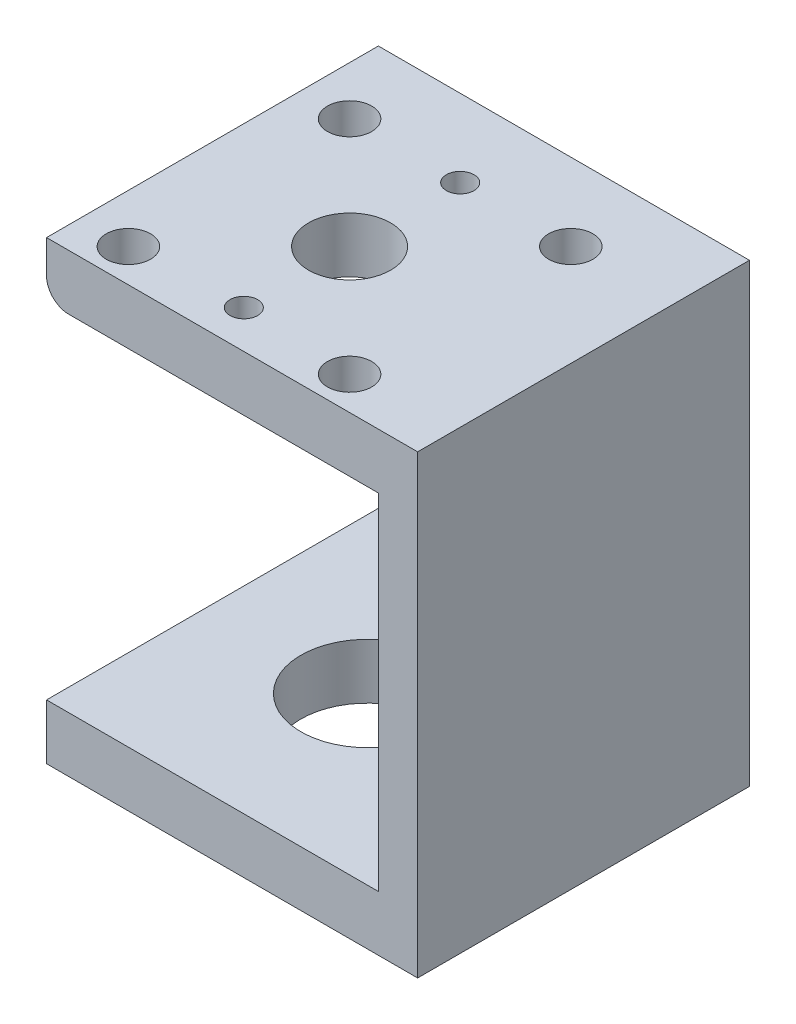
from build123d import *

# Parameters (mm, degrees)
CROQUIS1_W              = 33.552631578
CROQUIS1_H              = 30
SALIENTE_EXTRUIR1_DEPTH = 41.2
CROQUIS2_W              = 30
CROQUIS2_H              = 31.2
CORTAR_EXTRUIR1_DEPTH   = 36.2
CROQUIS3_R              = 2
CROQUIS3_R_2            = 1.25
CROQUIS3_R_3            = 3.71
CORTAR_EXTRUIR2_DEPTH   = 5
CROQUIS4_R              = 6
CORTAR_EXTRUIR3_DEPTH   = 5
REDONDEO1_R             = 2


with BuildPart() as part:
    # Croquis1 → Saliente-Extruir1 (new body)
    with BuildSketch(Plane(origin=(0, 0, 0), x_dir=(1, 0, 0), z_dir=(0, 1, 0))):
        Rectangle(CROQUIS1_W, CROQUIS1_H)
    extrude(amount=SALIENTE_EXTRUIR1_DEPTH)

    # Croquis2 → Cortar-Extruir1 (cut)
    with BuildSketch(Plane.XY.offset(15)):
        with Locations((-1.776315789, 20.6)):
            Rectangle(CROQUIS2_W, CROQUIS2_H)
    extrude(amount=-CORTAR_EXTRUIR1_DEPTH, mode=Mode.SUBTRACT)

    # Croquis3 → Cortar-Extruir2 (cut)
    with BuildSketch(Plane(origin=(0, 41.2, 0), x_dir=(1, 0, 0), z_dir=(0, 1, 0))):
        with Locations((-12.376315789, -12)):
            Circle(CROQUIS3_R)
        with Locations((-2.376315789, -11.563330836)):
            Circle(CROQUIS3_R_2)
        with Locations((7.623684211, -12)):
            Circle(CROQUIS3_R)
        with Locations((-2.376315789, -2)):
            Circle(CROQUIS3_R_3)
        with Locations((7.623684211, 8)):
            Circle(CROQUIS3_R)
        with Locations((-2.376315789, 8)):
            Circle(CROQUIS3_R_2)
        with Locations((-12.376315789, 8)):
            Circle(CROQUIS3_R)
    extrude(amount=-CORTAR_EXTRUIR2_DEPTH, mode=Mode.SUBTRACT)

    # Croquis4 → Cortar-Extruir3 (cut)
    with BuildSketch(Plane.XZ):
        with Locations((-2.779999999, 0)):
            Circle(CROQUIS4_R)
    extrude(amount=-CORTAR_EXTRUIR3_DEPTH, mode=Mode.SUBTRACT)

    # Redondeo1
    redondeo1_edges = [part.edges().sort_by_distance(p)[0] for p in [
        (-16.776315789, 36.2, 0),
    ]]
    fillet(redondeo1_edges, radius=REDONDEO1_R)


solid = part.part
